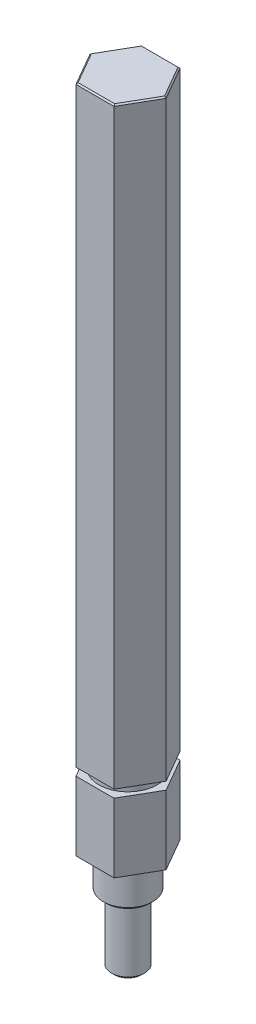
from build123d import *

# Parameters (mm, degrees)
BOSS_EXTRUDE1_DEPTH = 13.2842
SKETCH2_R           = 5.588
BOSS_EXTRUDE2_DEPTH = 1.4986
BOSS_EXTRUDE3_DEPTH = 114.04854
CHAMFER1_SIZE       = 0.508
CHAMFER2_SIZE       = 0.254


with BuildPart() as part:
    # Sketch1 → Boss-Extrude1 (new body)
    with BuildSketch(Plane.XZ.offset(25.4)):
        Polygon((-45.639482135, -16.669011646), (-41.973307925, -23.019011646), (-34.640959507, -23.019011646), (-30.974785297, -16.669011646), (-34.640959507, -10.319011646), (-41.973307925, -10.319011646), align=None)
    extrude(amount=-BOSS_EXTRUDE1_DEPTH)

    # Sketch2 → Boss-Extrude2 (add)
    with BuildSketch(Plane(origin=(0, -12.1158, 0), x_dir=(-1, 0, 0), z_dir=(0, 1, 0))):
        with Locations((38.307133716, -16.669011646)):
            Circle(SKETCH2_R)
    extrude(amount=BOSS_EXTRUDE2_DEPTH)

    # Sketch3 → Boss-Extrude3 (add)
    with BuildSketch(Plane.XZ.offset(10.6172)):
        Polygon((-45.639482135, -16.669011646), (-41.973307925, -23.019011646), (-34.640959507, -23.019011646), (-30.974785297, -16.669011646), (-34.640959507, -10.319011646), (-41.973307925, -10.319011646), align=None)
    extrude(amount=-BOSS_EXTRUDE3_DEPTH)

    # Sketch4 → Revolve1 (revolve)
    with BuildSketch(Plane(origin=(0, 0, -16.669011646), x_dir=(-1, 0, 0), z_dir=(0, 0, -1))):
        Polygon((35.144833716, -45.212), (38.307133716, -45.212), (38.307133716, -25.4), (33.557333716, -25.4), (33.557333716, -32.512), (35.144833716, -32.512), align=None)
    revolve(axis=Axis((-38.307133716, -45.212, -16.669011646), (0, 1, 0)))

    # Chamfer1
    chamfer1_edges = [part.edges().sort_by_distance(p)[0] for p in [
        (-41.469433716, -45.212, -16.669011646),
        (-43.056933716, -32.512, -16.669011646),
    ]]
    chamfer(chamfer1_edges, length=CHAMFER1_SIZE)

    # Chamfer2
    chamfer2_edges = [part.edges().sort_by_distance(p)[0] for p in [
        (-43.80639503, 103.43134, -13.494011646),
        (-38.307133716, 103.43134, -10.319011646),
        (-32.807872402, 103.43134, -13.494011646),
        (-32.807872402, 103.43134, -19.844011646),
        (-38.307133716, 103.43134, -23.019011646),
        (-43.80639503, 103.43134, -19.844011646),
    ]]
    chamfer(chamfer2_edges, length=CHAMFER2_SIZE)


solid = part.part
